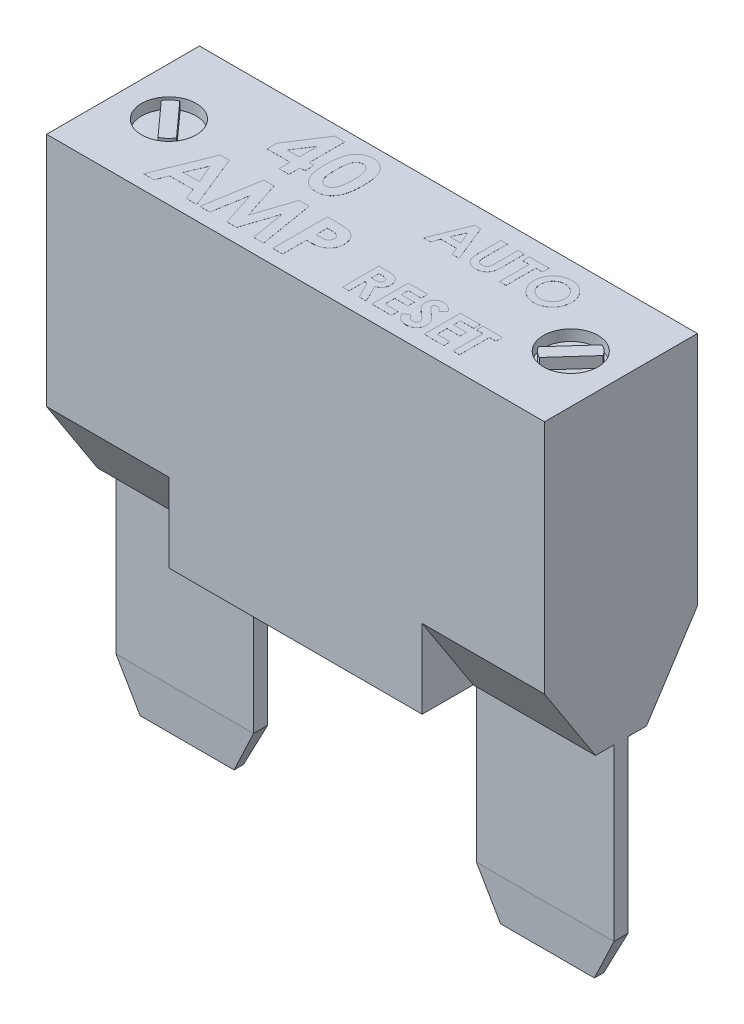
from build123d import *
from OCP.BRepFilletAPI import BRepFilletAPI_MakeChamfer

# Parameters (mm, degrees)
EXTRUDE1_DEPTH            = 14.478
SKETCH2_W                 = 8.89
SKETCH2_H                 = 18.288
EXTRUDE2_DEPTH            = 7.366
SKETCH3_W                 = 8.001
SKETCH3_H                 = 0.8128
EXTRUDE3_DEPTH            = 12.446
CHAMFER1_SIZE             = 2.54
CHAMFER1_SIZE2            = 0.133115759
CHAMFER2_SIZE             = 2.54
CHAMFER2_SIZE2            = 1.270274247
SKETCH4_R                 = 1.5875
EXTRUDE4_DEPTH            = 0.635
EXTRUDE5_DEPTH            = 0.635
CHAMFER1_OF_MIRROR1_SIZE  = 2.54
CHAMFER1_OF_MIRROR1_SIZE2 = 0.133115759
CHAMFER2_OF_MIRROR1_SIZE  = 2.54
CHAMFER2_OF_MIRROR1_SIZE2 = 1.270274247
EXTRUDE6_DEPTH            = 0.00254


with BuildPart() as part:
    # Sketch1 → Extrude1 (new, symmetric)
    with BuildSketch(Plane(origin=(0, 0, 0), x_dir=(0, 0, -1), z_dir=(1, 0, 0))):
        Polygon((-4.445, 4.572), (-1.481577724, 0), (1.481577724, 0), (4.445, 4.572), (4.445, 18.288), (-4.445, 18.288), align=None)
    extrude(amount=EXTRUDE1_DEPTH, both=True)

    # Sketch2 → Extrude2 (add, symmetric)
    with BuildSketch(Plane(origin=(0, 0, 0), x_dir=(0, 0, -1), z_dir=(1, 0, 0))):
        with Locations((0, 9.144)):
            Rectangle(SKETCH2_W, SKETCH2_H)
    extrude(amount=EXTRUDE2_DEPTH, both=True)

    # Sketch3 → Extrude3 (add)
    with BuildSketch(Plane.XZ):
        with Locations((-10.4775, 0)):
            Rectangle(SKETCH3_W, SKETCH3_H)
    extrude3 = extrude(amount=EXTRUDE3_DEPTH)

    # Chamfer1: one chamfer whose edges measure the first distance from different faces: ONE call of the kernel's chamfer builder (chamfer() names one face for all edges)
    chamfer1_edges_1 = [part.edges().sort_by_distance(p)[0] for p in [
        (-10.4775, -12.446, -0.4064),
    ]]
    chamfer1_side_1 = [part.faces().sort_by_distance(p)[0] for p in [
        (-10.4775, -6.223, -0.4064),
    ]]
    chamfer1_edges_2 = [part.edges().sort_by_distance(p)[0] for p in [
        (-10.4775, -12.446, 0.4064),
    ]]
    chamfer1_side_2 = [part.faces().sort_by_distance(p)[0] for p in [
        (-10.4775, -6.223, 0.4064),
    ]]
    chamfer1 = BRepFilletAPI_MakeChamfer(part.part.solid().wrapped)
    for e in chamfer1_edges_1:
        chamfer1.Add(CHAMFER1_SIZE, CHAMFER1_SIZE2, e.wrapped, chamfer1_side_1[0].wrapped)  # the first distance lies on this face
    for e in chamfer1_edges_2:
        chamfer1.Add(CHAMFER1_SIZE, CHAMFER1_SIZE2, e.wrapped, chamfer1_side_2[0].wrapped)  # the first distance lies on this face
    add(Compound.cast(chamfer1.Shape()), mode=Mode.REPLACE)

    # Chamfer2: one chamfer whose edges measure the first distance from different faces: ONE call of the kernel's chamfer builder (chamfer() names one face for all edges)
    chamfer2_edges_1 = [part.edges().sort_by_distance(p)[0] for p in [
        (-14.478, -12.446, 0),
    ]]
    chamfer2_side_1 = [part.faces().sort_by_distance(p)[0] for p in [
        (-14.478, 8.85938846, 0),
    ]]
    chamfer2_edges_2 = [part.edges().sort_by_distance(p)[0] for p in [
        (-6.477, -12.446, 0),
    ]]
    chamfer2_side_2 = [part.faces().sort_by_distance(p)[0] for p in [
        (-6.477, -6.037091359, 0),
    ]]
    chamfer2 = BRepFilletAPI_MakeChamfer(part.part.solid().wrapped)
    for e in chamfer2_edges_1:
        chamfer2.Add(CHAMFER2_SIZE, CHAMFER2_SIZE2, e.wrapped, chamfer2_side_1[0].wrapped)  # the first distance lies on this face
    for e in chamfer2_edges_2:
        chamfer2.Add(CHAMFER2_SIZE, CHAMFER2_SIZE2, e.wrapped, chamfer2_side_2[0].wrapped)  # the first distance lies on this face
    add(Compound.cast(chamfer2.Shape()), mode=Mode.REPLACE)

    # Sketch4 → Extrude4 (cut)
    with BuildSketch(Plane(origin=(0, 18.288, 0), x_dir=(1, 0, 0), z_dir=(0, 1, 0))):
        with Locations(Location((-11.684, -0.127, 0), (0, 0, 270))):
            Circle(SKETCH4_R)
        with Locations(Location((11.684, -0.127, 0), (0, 0, 90))):
            Circle(SKETCH4_R)
    extrude(amount=-EXTRUDE4_DEPTH, mode=Mode.SUBTRACT)

    # Sketch5 → Extrude5 (add)
    with BuildSketch(Plane(origin=(0, 17.653, 0), x_dir=(1, 0, 0), z_dir=(0, 1, 0))):
        with BuildLine():
            Line((-10.520386715, -0.849927911), (-12.281336928, 1.105805433))
            ThreePointArc((-12.281336928, 1.105805433), (-12.600640707, 0.89103264), (-12.847613285, 0.595927911))
            Line((-12.847613285, 0.595927911), (-11.086663072, -1.359805433))
            ThreePointArc((-11.086663072, -1.359805433), (-10.767359293, -1.14503264), (-10.520386715, -0.849927911))
        make_face()
    extrude5 = extrude(amount=EXTRUDE5_DEPTH)

    # Mirror1: Extrude3, Extrude5 across plane
    add(extrude3.mirror(Plane(origin=(0, 0, 0), x_dir=(0, 0, 1), z_dir=(1, 0, 0))))
    add(extrude5.mirror(Plane(origin=(0, 0, 0), x_dir=(0, 0, 1), z_dir=(1, 0, 0))))

    # Chamfer1 of Mirror1: one chamfer whose edges measure the first distance from different faces: ONE call of the kernel's chamfer builder (chamfer() names one face for all edges)
    chamfer1_of_mirror1_edges_1 = [part.edges().sort_by_distance(p)[0] for p in [
        (10.4775, -12.446, -0.4064),
    ]]
    chamfer1_of_mirror1_side_1 = [part.faces().sort_by_distance(p)[0] for p in [
        (10.4775, -6.223, -0.4064),
    ]]
    chamfer1_of_mirror1_edges_2 = [part.edges().sort_by_distance(p)[0] for p in [
        (10.4775, -12.446, 0.4064),
    ]]
    chamfer1_of_mirror1_side_2 = [part.faces().sort_by_distance(p)[0] for p in [
        (10.4775, -6.223, 0.4064),
    ]]
    chamfer1_of_mirror1 = BRepFilletAPI_MakeChamfer(part.part.solid().wrapped)
    for e in chamfer1_of_mirror1_edges_1:
        chamfer1_of_mirror1.Add(CHAMFER1_OF_MIRROR1_SIZE, CHAMFER1_OF_MIRROR1_SIZE2, e.wrapped, chamfer1_of_mirror1_side_1[0].wrapped)  # the first distance lies on this face
    for e in chamfer1_of_mirror1_edges_2:
        chamfer1_of_mirror1.Add(CHAMFER1_OF_MIRROR1_SIZE, CHAMFER1_OF_MIRROR1_SIZE2, e.wrapped, chamfer1_of_mirror1_side_2[0].wrapped)  # the first distance lies on this face
    add(Compound.cast(chamfer1_of_mirror1.Shape()), mode=Mode.REPLACE)

    # Chamfer2 of Mirror1: one chamfer whose edges measure the first distance from different faces: ONE call of the kernel's chamfer builder (chamfer() names one face for all edges)
    chamfer2_of_mirror1_edges_1 = [part.edges().sort_by_distance(p)[0] for p in [
        (14.478, -12.446, 0),
    ]]
    chamfer2_of_mirror1_side_1 = [part.faces().sort_by_distance(p)[0] for p in [
        (14.478, 8.85938846, 0),
    ]]
    chamfer2_of_mirror1_edges_2 = [part.edges().sort_by_distance(p)[0] for p in [
        (6.477, -12.446, 0),
    ]]
    chamfer2_of_mirror1_side_2 = [part.faces().sort_by_distance(p)[0] for p in [
        (6.477, -6.037091359, 0),
    ]]
    chamfer2_of_mirror1 = BRepFilletAPI_MakeChamfer(part.part.solid().wrapped)
    for e in chamfer2_of_mirror1_edges_1:
        chamfer2_of_mirror1.Add(CHAMFER2_OF_MIRROR1_SIZE, CHAMFER2_OF_MIRROR1_SIZE2, e.wrapped, chamfer2_of_mirror1_side_1[0].wrapped)  # the first distance lies on this face
    for e in chamfer2_of_mirror1_edges_2:
        chamfer2_of_mirror1.Add(CHAMFER2_OF_MIRROR1_SIZE, CHAMFER2_OF_MIRROR1_SIZE2, e.wrapped, chamfer2_of_mirror1_side_2[0].wrapped)  # the first distance lies on this face
    add(Compound.cast(chamfer2_of_mirror1.Shape()), mode=Mode.REPLACE)

    # Sketch7 → Extrude6 (add)
    with BuildSketch(Plane(origin=(0, 18.288, 0), x_dir=(1, 0, 0), z_dir=(0, 1, 0))):
        Polygon((-6.008239342, 3.833529575), (-5.414198877, 3.833529575), (-5.414198877, 1.757568037), (-5.129262979, 1.757568037), (-5.129262979, 1.22840137), (-5.414198877, 1.22840137), (-5.414198877, 0.577119319), (-5.984070672, 0.577119319), (-5.984070672, 1.22840137), (-7.327339903, 1.22840137), (-7.327339903, 1.805269359), align=None)
        Polygon((-5.984070672, 1.757568037), (-5.984070672, 2.838161987), (-6.686870151, 1.757568037), align=None, mode=Mode.SUBTRACT)
        with BuildLine():
            add(Edge.make_bspline(
                [(-3.775181449, 3.833529575), (-3.747597289, 3.833120081), (-3.69335946, 3.832314905), (-3.613477348, 3.823594194), (-3.536528788, 3.810419633), (-3.462212747, 3.792045714), (-3.391064161, 3.767728487), (-3.322565195, 3.738621183), (-3.257531185, 3.703197064), (-3.19513274, 3.663183703), (-3.135393895, 3.617882905), (-3.079750432, 3.566237656), (-3.027186183, 3.509436316), (-2.97883897, 3.44662015), (-2.933638131, 3.378360538), (-2.891732186, 3.304646657), (-2.853441936, 3.225117725), (-2.81833824, 3.139630227), (-2.786948404, 3.046902742), (-2.760508784, 2.945871645), (-2.737832386, 2.836513865), (-2.718691906, 2.718557193), (-2.704224796, 2.591844837), (-2.694473673, 2.456460977), (-2.687781991, 2.312666615), (-2.687235863, 2.214024865), (-2.686955287, 2.163347284)],
                knots=[0, 0, 0, 0, 0.879237366, 1.728815576, 2.559023295, 3.367336655, 4.166867292, 4.954216142, 5.737608147, 6.525189134, 7.316157332, 8.124696809, 8.942788509, 9.781158001, 10.649253743, 11.551476218, 12.482711956, 13.461909668, 14.496590415, 15.601789533, 16.789733467, 18.056700938, 19.410929216, 20.8549011, 22.384193279, 24, 24, 24, 24], degree=3))
            add(Edge.make_bspline(
                [(-2.686955287, 2.163347284), (-2.687258514, 2.112035669), (-2.687847677, 2.012338123), (-2.694195498, 1.867228544), (-2.705126746, 1.730861717), (-2.719215727, 1.603251749), (-2.738513778, 1.484466028), (-2.761114477, 1.374196981), (-2.787971439, 1.272484576), (-2.820395246, 1.179557993), (-2.855286458, 1.09392036), (-2.893681448, 1.01454649), (-2.934910995, 0.941221396), (-2.978029419, 0.872838869), (-3.025400628, 0.811414789), (-3.074718935, 0.754860419), (-3.128131744, 0.705329986), (-3.183390172, 0.660270913), (-3.242518556, 0.621330833), (-3.304907123, 0.58727448), (-3.371668151, 0.559650733), (-3.4415847, 0.535625073), (-3.515848514, 0.518377242), (-3.593279548, 0.504691655), (-3.674751986, 0.49712816), (-3.730221702, 0.496189858), (-3.758644991, 0.495709062)],
                knots=[0, 0, 0, 0, 1.643780988, 3.193836972, 4.651895693, 6.025988579, 7.305620092, 8.505800249, 9.631074763, 10.672816429, 11.65661981, 12.592235626, 13.49536222, 14.350718032, 15.179365177, 15.97804903, 16.751647189, 17.51006938, 18.259804725, 19.016521909, 19.783502495, 20.571750527, 21.382245291, 22.22305063, 23.089471752, 24, 24, 24, 24], degree=3))
            add(Edge.make_bspline(
                [(-3.758644991, 0.495709062), (-3.787067512, 0.496199133), (-3.842746812, 0.497159173), (-3.924439559, 0.504635417), (-4.00228094, 0.518432682), (-4.077132299, 0.535757489), (-4.148472683, 0.559597574), (-4.216644168, 0.588047803), (-4.281122573, 0.621891661), (-4.34208643, 0.660922469), (-4.399327589, 0.705680062), (-4.453735579, 0.755685708), (-4.505190045, 0.810812655), (-4.552908238, 0.87167837), (-4.597671644, 0.937470424), (-4.639013451, 1.008940129), (-4.676908813, 1.085983428), (-4.712543106, 1.168707711), (-4.743504795, 1.258893936), (-4.771059261, 1.357347456), (-4.793631155, 1.464888961), (-4.811784982, 1.581483903), (-4.826278988, 1.70688527), (-4.837060862, 1.84115359), (-4.843443942, 1.984351402), (-4.844026927, 2.082778391), (-4.844327082, 2.133454455)],
                knots=[0, 0, 0, 0, 0.917216111, 1.796812873, 2.643793957, 3.46689424, 4.273913431, 5.068098542, 5.848489301, 6.620921603, 7.401012384, 8.190319798, 9.003608147, 9.831726257, 10.68377682, 11.569763213, 12.493818149, 13.453288342, 14.474581811, 15.568529029, 16.750744269, 18.018426408, 19.375425659, 20.823733699, 22.36466933, 24, 24, 24, 24], degree=3))
            add(Edge.make_bspline(
                [(-4.844327082, 2.133454455), (-4.843783379, 2.203864856), (-4.842734297, 2.339722633), (-4.829439555, 2.535997619), (-4.809926247, 2.717419844), (-4.781265819, 2.883685834), (-4.745827597, 3.035411388), (-4.700447108, 3.171597018), (-4.648784722, 3.294127158), (-4.604761733, 3.366714751), (-4.583559854, 3.401673606)],
                knots=[0, 0, 0, 0, 1.288568992, 2.486310467, 3.599230591, 4.627010532, 5.572937695, 6.447898582, 7.252493626, 8, 8, 8, 8], degree=3))
            add(Edge.make_bspline(
                [(-4.583559854, 3.401673606), (-4.55890732, 3.436017174), (-4.510706758, 3.503165617), (-4.426426728, 3.591318971), (-4.335878809, 3.666712036), (-4.237203198, 3.727638599), (-4.131960491, 3.775685292), (-4.019247126, 3.80962013), (-3.899479335, 3.829392148), (-3.817232794, 3.832129838), (-3.775181449, 3.833529575)],
                knots=[0, 0, 0, 0, 1.058512271, 2.069600068, 3.047294572, 4.004278952, 4.967380941, 5.939006123, 6.946246673, 8, 8, 8, 8], degree=3))
        make_face()
        with BuildLine():
            add(Edge.make_bspline(
                [(-3.761189061, 3.26365778), (-3.786125371, 3.262475849), (-3.835013774, 3.260158636), (-3.905953177, 3.240488766), (-3.972844605, 3.21010759), (-4.023727127, 3.173548596), (-4.061812189, 3.138502416), (-4.088422495, 3.106786763), (-4.114083941, 3.07139438), (-4.136749423, 3.03072819), (-4.158151554, 2.986249378), (-4.179067887, 2.937756038), (-4.196213788, 2.884057066), (-4.21305918, 2.826066965), (-4.227817317, 2.762182461), (-4.240181399, 2.691881369), (-4.25122762, 2.614706515), (-4.258932491, 2.530607349), (-4.266115743, 2.43967186), (-4.271265038, 2.341697479), (-4.273417829, 2.236710636), (-4.274102136, 2.164407756), (-4.274455287, 2.127094279)],
                knots=[0, 0, 0, 0, 1.076674018, 2.110852608, 3.161083442, 4.239746716, 4.804137807, 5.395870207, 6.026861976, 6.692161227, 7.405688833, 8.16177676, 8.973626916, 9.841385931, 10.773283133, 11.807421078, 12.927755683, 14.143907515, 15.458935494, 16.872852025, 18.386167141, 20, 20, 20, 20], degree=3))
            add(Edge.make_bspline(
                [(-4.274455287, 2.127094279), (-4.273874043, 2.078752865), (-4.272759464, 1.986054621), (-4.266921819, 1.852751318), (-4.255220744, 1.731434579), (-4.240666969, 1.621282194), (-4.220225599, 1.523008532), (-4.196706478, 1.435683833), (-4.167662456, 1.360421274), (-4.134096492, 1.296132389), (-4.096920675, 1.241441969), (-4.05656469, 1.194954865), (-4.014402514, 1.154699227), (-3.969118128, 1.122000068), (-3.920819567, 1.09694094), (-3.869910036, 1.078916218), (-3.816357182, 1.067882536), (-3.77968474, 1.066352519), (-3.761189061, 1.065580857)],
                knots=[0, 0, 0, 0, 1.771748488, 3.397459088, 4.888034009, 6.237357457, 7.467047327, 8.564189669, 9.548206622, 10.417051504, 11.216568818, 11.965764335, 12.669334354, 13.348544111, 14.005342236, 14.656555988, 15.322436492, 16, 16, 16, 16], degree=3))
            add(Edge.make_bspline(
                [(-3.761189061, 1.065580857), (-3.743328096, 1.066108885), (-3.708358546, 1.067142698), (-3.657365111, 1.077754651), (-3.609142095, 1.095007382), (-3.563835099, 1.11941258), (-3.521282066, 1.150447524), (-3.481690969, 1.188248594), (-3.445360397, 1.233192579), (-3.42419404, 1.266547663), (-3.413287419, 1.283734904)],
                knots=[0, 0, 0, 0, 0.992283464, 1.942767638, 2.88273346, 3.832339453, 4.79467288, 5.803907806, 6.868395428, 8, 8, 8, 8], degree=3))
            add(Edge.make_bspline(
                [(-3.413287419, 1.283734904), (-3.400446709, 1.307220719), (-3.373520782, 1.356468569), (-3.342362053, 1.439572479), (-3.316134371, 1.533299955), (-3.293560589, 1.637942685), (-3.278121499, 1.753913393), (-3.264825374, 1.880476699), (-3.258412322, 2.018269924), (-3.257369204, 2.113733567), (-3.256827082, 2.163347284)],
                knots=[0, 0, 0, 0, 0.710965849, 1.490837728, 2.352621235, 3.297892224, 4.334225155, 5.461620853, 6.680770821, 8, 8, 8, 8], degree=3))
            add(Edge.make_bspline(
                [(-3.256827082, 2.163347284), (-3.257036492, 2.213391671), (-3.257439571, 2.309718575), (-3.264834896, 2.448007176), (-3.275133451, 2.574310862), (-3.290197265, 2.688347648), (-3.309579599, 2.790394366), (-3.333468398, 2.880444345), (-3.361631516, 2.958675056), (-3.395029618, 3.025008491), (-3.43202009, 3.081382812), (-3.471286606, 3.129747606), (-3.5129952, 3.171040248), (-3.557076122, 3.205416127), (-3.604549639, 3.231681878), (-3.654508947, 3.25022767), (-3.707056465, 3.261447253), (-3.742901311, 3.262910992), (-3.761189061, 3.26365778)],
                knots=[0, 0, 0, 0, 1.793836731, 3.452829483, 4.963243077, 6.335886805, 7.574563692, 8.684454726, 9.672768357, 10.54971625, 11.340229787, 12.085688095, 12.778991901, 13.440269426, 14.083255152, 14.715733572, 15.344777694, 16, 16, 16, 16], degree=3))
        make_face(mode=Mode.SUBTRACT)
        Polygon((-8.381308192, -0.44156083), (-7.852777543, -0.44156083), (-6.570566004, -3.61656083), (-7.179234874, -3.61656083), (-7.426009714, -2.965278779), (-8.809348055, -2.965278779), (-9.056122895, -3.61656083), (-9.664155748, -3.61656083), align=None)
        Polygon((-8.117360876, -1.293188434), (-8.593102062, -2.395406984), (-7.64161969, -2.395406984), align=None, mode=Mode.SUBTRACT)
        Polygon((-5.851230067, -0.44156083), (-5.259733672, -0.44156083), (-4.535309594, -2.656174212), (-3.805797374, -0.44156083), (-3.220025139, -0.44156083), (-2.683226261, -3.61656083), (-3.260094249, -3.61656083), (-3.599091645, -1.611197248), (-4.259277943, -3.61656083), (-4.81515735, -3.61656083), (-5.471527543, -1.611197248), (-5.809888921, -3.61656083), (-6.387392927, -3.61656083), align=None)
        with BuildLine():
            Line((-2.154059594, -0.44156083), (-1.518041966, -0.44156083))
            add(Edge.make_bspline(
                [(-1.518041966, -0.44156083), (-1.476485399, -0.441746846), (-1.396314071, -0.44210571), (-1.28070042, -0.446457413), (-1.174041166, -0.454255929), (-1.076360814, -0.463893661), (-0.987699528, -0.477405387), (-0.907946277, -0.492895523), (-0.837084511, -0.511767016), (-0.774315157, -0.534167218), (-0.71798169, -0.56057618), (-0.664672061, -0.58870361), (-0.615591073, -0.622272705), (-0.568261461, -0.657665532), (-0.52538914, -0.698263153), (-0.484299479, -0.741363737), (-0.446732736, -0.788676619), (-0.412514841, -0.839629089), (-0.381473939, -0.893279762), (-0.354354529, -0.949724551), (-0.332356783, -1.009052774), (-0.313903409, -1.070880643), (-0.29908148, -1.135205465), (-0.289215531, -1.202422844), (-0.282514083, -1.27206344), (-0.281922773, -1.319460875), (-0.281623696, -1.343433827)],
                knots=[0, 0, 0, 0, 1.698747864, 3.27724071, 4.728299578, 6.070144658, 7.288476769, 8.393259625, 9.389771311, 10.283485332, 11.113357557, 11.931608583, 12.74405601, 13.541433047, 14.344816069, 15.154114104, 15.974336324, 16.810834471, 17.661136416, 18.50621059, 19.367396281, 20.244825668, 21.142564693, 22.063065223, 23.020325768, 24, 24, 24, 24], degree=3))
            add(Edge.make_bspline(
                [(-0.281623696, -1.343433827), (-0.282056423, -1.369954533), (-0.282906782, -1.42207098), (-0.29124305, -1.498467297), (-0.305484029, -1.571304269), (-0.324096243, -1.641196142), (-0.350049653, -1.706993041), (-0.379700204, -1.770264899), (-0.416179788, -1.829237769), (-0.457863543, -1.884649328), (-0.50338696, -1.936950101), (-0.553830762, -1.98463), (-0.608233468, -2.028014057), (-0.66628016, -2.067556943), (-0.728188764, -2.103178888), (-0.79391461, -2.135213456), (-0.863906509, -2.162636081), (-0.912646763, -2.176977892), (-0.937357871, -2.184249131)],
                knots=[0, 0, 0, 0, 1.102006807, 2.165578795, 3.188629044, 4.184801286, 5.166646146, 6.124351954, 7.085497154, 8.042432466, 9.003981491, 9.963833307, 10.922997304, 11.89326795, 12.880200226, 13.889073926, 14.929769137, 16, 16, 16, 16], degree=3))
            add(Edge.make_bspline(
                [(-0.937357871, -2.184249131), (-0.953634029, -2.188298666), (-0.988893427, -2.197071261), (-1.047238047, -2.205977647), (-1.114474096, -2.214166522), (-1.190818991, -2.221203868), (-1.276316748, -2.225987624), (-1.370884582, -2.229723524), (-1.47456535, -2.23243991), (-1.546660856, -2.232536299), (-1.584187799, -2.232586471)],
                knots=[0, 0, 0, 0, 0.618981996, 1.340914327, 2.176866532, 3.120127938, 4.170906482, 5.338178032, 6.614476169, 8, 8, 8, 8], degree=3))
            Line((-1.584187799, -2.232586471), (-1.584187799, -3.61656083))
            Line((-1.584187799, -3.61656083), (-2.154059594, -3.61656083))
            Line((-2.154059594, -3.61656083), (-2.154059594, -0.44156083))
        make_face()
        with BuildLine():
            Line((-1.584187799, -1.662714676), (-1.382570211, -1.662714676))
            add(Edge.make_bspline(
                [(-1.382570211, -1.662714676), (-1.345882708, -1.662482049), (-1.278377157, -1.662054012), (-1.186188412, -1.655864339), (-1.112103764, -1.646411459), (-1.053575516, -1.632853843), (-1.007361921, -1.612278366), (-0.967505588, -1.588476413), (-0.933319794, -1.558379497), (-0.903719928, -1.523988621), (-0.880055728, -1.484471781), (-0.863645837, -1.440472431), (-0.852986295, -1.392915046), (-0.852001787, -1.359818253), (-0.851495491, -1.342797809)],
                knots=[0, 0, 0, 0, 1.8619151, 3.425951444, 4.686033666, 5.651700536, 6.461346321, 7.243864085, 7.999046032, 8.762387399, 9.539336099, 10.322741239, 11.137448474, 12, 12, 12, 12], degree=3))
            add(Edge.make_bspline(
                [(-0.851495491, -1.342797809), (-0.851996579, -1.327927269), (-0.852968809, -1.299074846), (-0.860111079, -1.257433642), (-0.871493802, -1.21861545), (-0.88798693, -1.183025674), (-0.90930864, -1.150724787), (-0.935304119, -1.121725514), (-0.965639794, -1.09540681), (-0.989060708, -1.081475918), (-1.000959634, -1.07439837)],
                knots=[0, 0, 0, 0, 1.102301479, 2.1387299, 3.123554645, 4.094223062, 5.036071848, 5.982632524, 6.975082478, 8, 8, 8, 8], degree=3))
            add(Edge.make_bspline(
                [(-1.000959634, -1.07439837), (-1.011038711, -1.069301092), (-1.032378182, -1.058509109), (-1.068721371, -1.045962641), (-1.110660855, -1.035378312), (-1.158479775, -1.026593422), (-1.211987366, -1.019775434), (-1.271174082, -1.01456138), (-1.336127021, -1.012464605), (-1.381297904, -1.011786106), (-1.404830828, -1.011432625)],
                knots=[0, 0, 0, 0, 0.656809284, 1.390599849, 2.23162475, 3.173112763, 4.218524733, 5.370385145, 6.63003504, 8, 8, 8, 8], degree=3))
            Line((-1.404830828, -1.011432625), (-1.584187799, -1.011432625))
            Line((-1.584187799, -1.011432625), (-1.584187799, -1.662714676))
        make_face(mode=Mode.SUBTRACT)
        Polygon((2.557586423, 3.413395415), (2.909940189, 3.413395415), (3.764747882, 1.296728748), (3.358968635, 1.296728748), (3.194452075, 1.730916783), (2.272226514, 1.730916783), (2.107709954, 1.296728748), (1.702354719, 1.296728748), align=None)
        Polygon((2.733551301, 2.845643679), (2.41639051, 2.110831313), (3.050712091, 2.110831313), align=None, mode=Mode.SUBTRACT)
        with BuildLine():
            Line((4.076820531, 3.413395415), (4.456735061, 3.413395415))
            Line((4.456735061, 3.413395415), (4.456735061, 2.036205244))
            add(Edge.make_bspline(
                [(4.456735061, 2.036205244), (4.456755719, 2.021927134), (4.45679562, 1.994349111), (4.458793058, 1.954783678), (4.460620853, 1.91841476), (4.463918712, 1.885282175), (4.468790781, 1.855371749), (4.473508534, 1.828491349), (4.479893545, 1.805122236), (4.489489196, 1.778522068), (4.504272945, 1.748635327), (4.52842877, 1.717486679), (4.556302526, 1.689059017), (4.589710828, 1.665396908), (4.627258805, 1.646256395), (4.668740148, 1.632075393), (4.714096381, 1.624192639), (4.745457729, 1.622989192), (4.761599511, 1.622369774)],
                knots=[0, 0, 0, 0, 1.155499968, 2.231836252, 3.205919964, 4.102923608, 4.924856345, 5.658536265, 6.31071849, 6.882491295, 7.94666036, 8.992281882, 10.060072772, 11.158554251, 12.289267114, 13.461410017, 14.693379945, 16, 16, 16, 16], degree=3))
            add(Edge.make_bspline(
                [(4.761599511, 1.622369774), (4.778748162, 1.622870184), (4.812185129, 1.623845899), (4.860278883, 1.633423597), (4.904838018, 1.648674572), (4.944919066, 1.6704416), (4.980482141, 1.696533197), (5.010585538, 1.726285795), (5.034343028, 1.759758735), (5.049827277, 1.79064007), (5.05852092, 1.819063651), (5.065037238, 1.844459041), (5.069814421, 1.874423088), (5.074148437, 1.908487838), (5.076752848, 1.947006136), (5.079576906, 1.989668214), (5.080611949, 2.036765977), (5.080788365, 2.069561033), (5.08088036, 2.086662643)],
                knots=[0, 0, 0, 0, 1.261321664, 2.459363699, 3.594844139, 4.716940403, 5.803436589, 6.833651888, 7.818396249, 8.814403945, 9.360733334, 10.004355033, 10.743453831, 11.592799886, 12.532235708, 13.585170094, 14.740740724, 16, 16, 16, 16], degree=3))
            Line((5.08088036, 2.086662643), (5.08088036, 3.413395415))
            Line((5.08088036, 3.413395415), (5.46079489, 3.413395415))
            Line((5.46079489, 3.413395415), (5.46079489, 2.150688417))
            add(Edge.make_bspline(
                [(5.46079489, 2.150688417), (5.460742132, 2.125106034), (5.460640684, 2.075913605), (5.45908274, 2.005220624), (5.455766159, 1.940653925), (5.452980613, 1.882194643), (5.447589628, 1.829921531), (5.441973487, 1.783611369), (5.434815232, 1.743428269), (5.424164179, 1.697684693), (5.405783614, 1.64501264), (5.376151734, 1.584363055), (5.33853598, 1.524983437), (5.294076038, 1.467527004), (5.243876697, 1.414151829), (5.189050984, 1.367295334), (5.130469943, 1.327659792), (5.067521443, 1.296214339), (5.000259058, 1.271689257), (4.928017276, 1.255209637), (4.85084536, 1.244075799), (4.79754126, 1.243006257), (4.770079746, 1.242455244)],
                knots=[0, 0, 0, 0, 1.170808336, 2.251350247, 3.235597562, 4.129743112, 4.929140599, 5.639994148, 6.264258765, 6.79612947, 7.788252245, 8.809469599, 9.879094798, 10.999557536, 12.129761673, 13.226370002, 14.293821979, 15.358369427, 16.438775801, 17.562147481, 18.744053101, 20, 20, 20, 20], degree=3))
            add(Edge.make_bspline(
                [(4.770079746, 1.242455244), (4.75183377, 1.242762574), (4.715834834, 1.243368928), (4.662892083, 1.248715391), (4.611712514, 1.256594068), (4.562392293, 1.268088245), (4.51476024, 1.282936575), (4.468829008, 1.301213836), (4.424769289, 1.322818079), (4.382827636, 1.347550591), (4.34305566, 1.374294546), (4.306706128, 1.403941345), (4.272528165, 1.434298497), (4.24150916, 1.466643558), (4.213416132, 1.500636961), (4.188306938, 1.536355747), (4.166218882, 1.573796742), (4.146596353, 1.613634818), (4.129801382, 1.6578948), (4.115642591, 1.708151036), (4.103273138, 1.76519124), (4.09408089, 1.829143921), (4.085747145, 1.899798299), (4.080472343, 1.977338439), (4.077712857, 2.061766566), (4.077125489, 2.120298836), (4.076820531, 2.150688417)],
                knots=[0, 0, 0, 0, 1.001158378, 1.975264943, 2.917723546, 3.841610987, 4.75185031, 5.653588123, 6.552117133, 7.442167995, 8.324307438, 9.179605724, 10.014504199, 10.831958861, 11.636465792, 12.43274043, 13.225645099, 14.020104002, 14.867201867, 15.819789774, 16.883317127, 18.068162734, 19.364263498, 20.787406516, 22.332041935, 24, 24, 24, 24], degree=3))
            Line((4.076820531, 2.150688417), (4.076820531, 3.413395415))
        make_face()
        Polygon((5.732162412, 3.413395415), (6.871906001, 3.413395415), (6.871906001, 3.033480885), (6.491991472, 3.033480885), (6.491991472, 1.296728748), (6.112076942, 1.296728748), (6.112076942, 3.033480885), (5.732162412, 3.033480885), align=None)
        with BuildLine():
            add(Edge.make_bspline(
                [(8.165141845, 3.467668919), (8.20194269, 3.46671608), (8.274595891, 3.464834958), (8.381442533, 3.449154342), (8.484409028, 3.423605027), (8.583448815, 3.388089631), (8.67831391, 3.341646216), (8.769338935, 3.285591484), (8.856197841, 3.218867435), (8.938000568, 3.143030632), (9.013601042, 3.06056142), (9.079108896, 2.971768652), (9.134971591, 2.878953037), (9.181270743, 2.781865872), (9.216536164, 2.679834784), (9.241283369, 2.573379996), (9.257182222, 2.462531793), (9.259010834, 2.387059276), (9.259940189, 2.348701905)],
                knots=[0, 0, 0, 0, 1.014329547, 2.002516266, 2.970391464, 3.935626869, 4.897733899, 5.877609409, 6.878433252, 7.912639331, 8.949961323, 9.958554974, 10.949718813, 11.932905612, 12.9188844, 13.919928257, 14.942845884, 16, 16, 16, 16], degree=3))
            add(Edge.make_bspline(
                [(9.259940189, 2.348701905), (9.258950466, 2.310776734), (9.257000185, 2.236043967), (9.241932429, 2.126217274), (9.216768479, 2.020902838), (9.182101186, 1.919862279), (9.136641727, 1.823585), (9.081868415, 1.731456287), (9.016335888, 1.644331115), (8.942434373, 1.562256238), (8.86107522, 1.487755676), (8.77490296, 1.422102185), (8.684315485, 1.366469894), (8.589445386, 1.320884286), (8.490089218, 1.285506974), (8.386492403, 1.26054571), (8.278661352, 1.245376245), (8.205331008, 1.243438703), (8.168109928, 1.242455244)],
                knots=[0, 0, 0, 0, 1.051557043, 2.072126891, 3.067553643, 4.050577992, 5.02905126, 6.015227836, 7.017913613, 8.04756643, 9.074058332, 10.072836633, 11.047628519, 12.017157415, 12.98668631, 13.966869689, 14.968021931, 16, 16, 16, 16], degree=3))
            add(Edge.make_bspline(
                [(8.168109928, 1.242455244), (8.129181141, 1.243337456), (8.052691395, 1.245070881), (7.94074831, 1.26155496), (7.833497162, 1.286385742), (7.731838923, 1.323444352), (7.634738289, 1.369770731), (7.542908688, 1.426824444), (7.456380981, 1.494511205), (7.375651504, 1.571097532), (7.302510403, 1.654899771), (7.237949034, 1.743429406), (7.183490088, 1.836010147), (7.139131571, 1.932685324), (7.104161098, 2.032854125), (7.079493402, 2.137126606), (7.064921606, 2.245252684), (7.06289184, 2.318694078), (7.061863266, 2.355910105)],
                knots=[0, 0, 0, 0, 1.067978421, 2.098431617, 3.099715153, 4.085208694, 5.062210972, 6.048429807, 7.046490867, 8.072918869, 9.098532598, 10.095778865, 11.076610158, 12.041847152, 13.011192615, 13.984257998, 14.978533688, 16, 16, 16, 16], degree=3))
            add(Edge.make_bspline(
                [(7.061863266, 2.355910105), (7.062186092, 2.3809471), (7.062827655, 2.430704064), (7.070555962, 2.504441346), (7.081682501, 2.576739374), (7.098138124, 2.647309896), (7.1181275, 2.716650755), (7.144026561, 2.784116508), (7.173506701, 2.850427875), (7.207951469, 2.914801636), (7.246250721, 2.976645498), (7.288038614, 3.035667733), (7.333420225, 3.091154676), (7.382249363, 3.143470965), (7.4346943, 3.192272721), (7.490065178, 3.238250799), (7.549435869, 3.28018386), (7.611506935, 3.319095992), (7.675928434, 3.354283558), (7.742438112, 3.384234162), (7.809665737, 3.410389514), (7.87850938, 3.431032475), (7.94823126, 3.44784595), (8.019576213, 3.45896499), (8.091899679, 3.466693082), (8.14066985, 3.467342868), (8.165141845, 3.467668919)],
                knots=[0, 0, 0, 0, 1.034744296, 2.056386356, 3.06226378, 4.057406941, 5.050368692, 6.043467995, 7.042652155, 8.049140477, 9.059438543, 10.048523776, 11.036952808, 12.020949711, 13.004946614, 13.997082645, 14.994316842, 16.007702937, 17.024872941, 18.026463647, 19.021641123, 20.005082605, 20.995858141, 21.984425357, 22.988620895, 24, 24, 24, 24], degree=3))
        make_face()
        with BuildLine():
            add(Edge.make_bspline(
                [(8.159205681, 3.087754389), (8.134438718, 3.087089836), (8.085558643, 3.085778274), (8.013860476, 3.075785944), (7.945027703, 3.059827058), (7.879441892, 3.036710807), (7.816818788, 3.007289685), (7.757047381, 2.971666495), (7.70095538, 2.928616728), (7.647794852, 2.880451536), (7.599773063, 2.826784442), (7.557344298, 2.769271025), (7.521838255, 2.708007329), (7.492101722, 2.643562481), (7.469716703, 2.575211815), (7.453772526, 2.50349073), (7.4436964, 2.428275645), (7.442426292, 2.377001621), (7.441777796, 2.350821964)],
                knots=[0, 0, 0, 0, 1.033739768, 2.040188636, 3.016340934, 3.979330865, 4.937572243, 5.900995986, 6.878200029, 7.884839167, 8.891893314, 9.879764717, 10.863503415, 11.843163062, 12.837761627, 13.859916423, 14.907309254, 16, 16, 16, 16], degree=3))
            add(Edge.make_bspline(
                [(7.441777796, 2.350821964), (7.442637603, 2.321809016), (7.444322681, 2.264948445), (7.456179097, 2.182001775), (7.476464245, 2.103666878), (7.505755603, 2.030326878), (7.542084573, 1.961167389), (7.587199387, 1.89703606), (7.6403694, 1.8375489), (7.681331147, 1.802817819), (7.702121012, 1.785190287)],
                knots=[0, 0, 0, 0, 1.078454662, 2.113592447, 3.107694534, 4.079536787, 5.043276885, 6.005368276, 6.987637804, 8, 8, 8, 8], degree=3))
            add(Edge.make_bspline(
                [(7.702121012, 1.785190287), (7.719151881, 1.772167744), (7.752829909, 1.746416057), (7.806587375, 1.713409988), (7.861946979, 1.685120494), (7.91932648, 1.662262917), (7.978604694, 1.644283532), (8.039773494, 1.631692864), (8.102746207, 1.623791131), (8.145331307, 1.622846724), (8.166837892, 1.622369774)],
                knots=[0, 0, 0, 0, 1.023928204, 2.024787132, 3.009472467, 3.9914905, 4.972207045, 5.96565515, 6.972602802, 8, 8, 8, 8], degree=3))
            add(Edge.make_bspline(
                [(8.166837892, 1.622369774), (8.191178987, 1.623039962), (8.239070856, 1.624358578), (8.309434324, 1.634227896), (8.376844663, 1.650930347), (8.441720362, 1.673843814), (8.50387435, 1.703634344), (8.563002862, 1.740362453), (8.619209567, 1.78357717), (8.672302368, 1.832374877), (8.720831699, 1.886253382), (8.763171924, 1.94407357), (8.799806881, 2.004561491), (8.828925043, 2.068573257), (8.852194443, 2.13550463), (8.867946725, 2.205652032), (8.87810797, 2.27872629), (8.879378436, 2.328455906), (8.88002566, 2.353790047)],
                knots=[0, 0, 0, 0, 1.026359118, 2.019393844, 2.989460624, 3.950973911, 4.916101784, 5.890408035, 6.881132271, 7.902007068, 8.92769091, 9.933912415, 10.920395702, 11.90457117, 12.894218921, 13.903490204, 14.931958862, 16, 16, 16, 16], degree=3))
            add(Edge.make_bspline(
                [(8.88002566, 2.353790047), (8.879356042, 2.378978509), (8.878038003, 2.428558157), (8.868151314, 2.501444541), (8.851554786, 2.571282264), (8.828572511, 2.638185375), (8.799225364, 2.702219467), (8.762934639, 2.763159356), (8.719827676, 2.820946129), (8.670896579, 2.875185992), (8.617638087, 2.925028951), (8.560459775, 2.968283579), (8.500961556, 3.005870475), (8.437778249, 3.035314532), (8.372202534, 3.05877255), (8.303834263, 3.076047371), (8.232414487, 3.085708077), (8.183826137, 3.087066205), (8.159205681, 3.087754389)],
                knots=[0, 0, 0, 0, 1.055025985, 2.07665775, 3.074803781, 4.057872707, 5.035505728, 6.020516407, 7.023567878, 8.050795229, 9.077271434, 10.074415901, 11.050397877, 12.019801805, 12.988065821, 13.964604439, 14.968634123, 16, 16, 16, 16], degree=3))
        make_face(mode=Mode.SUBTRACT)
        with BuildLine():
            Line((1.82253207, -1.424321113), (2.26520034, -1.424321113))
            add(Edge.make_bspline(
                [(2.26520034, -1.424321113), (2.294460577, -1.42442497), (2.350736257, -1.424624717), (2.431882713, -1.427776185), (2.506426893, -1.432161712), (2.574479165, -1.438854143), (2.636010416, -1.447727497), (2.691082314, -1.458187714), (2.73969325, -1.470109373), (2.782253191, -1.484964701), (2.820661432, -1.501721285), (2.856463253, -1.520974908), (2.890448494, -1.542511175), (2.922390002, -1.566896761), (2.952565355, -1.593692978), (2.981031481, -1.622926798), (3.007386127, -1.654846111), (3.031466104, -1.689249229), (3.053413065, -1.72544052), (3.072809576, -1.763469675), (3.08858285, -1.803363141), (3.102520229, -1.84454437), (3.112558872, -1.887602058), (3.119540601, -1.932117029), (3.12465235, -1.978245982), (3.124946251, -2.009583945), (3.125096173, -2.025569778)],
                knots=[0, 0, 0, 0, 1.749336639, 3.364467119, 4.854658419, 6.213483162, 7.451590619, 8.570285859, 9.5643256, 10.440900261, 11.26203566, 12.067320669, 12.869050712, 13.665104639, 14.467235401, 15.27997916, 16.102287765, 16.939272006, 17.78853747, 18.631303466, 19.488103222, 20.351255419, 21.228522269, 22.127379805, 23.044756219, 24, 24, 24, 24], degree=3))
            add(Edge.make_bspline(
                [(3.125096173, -2.025569778), (3.124706729, -2.042255315), (3.123943101, -2.074972613), (3.119829783, -2.123031654), (3.112311931, -2.169011184), (3.10092505, -2.212776579), (3.08783731, -2.254872551), (3.070433972, -2.294522402), (3.050792586, -2.332302783), (3.027465085, -2.367679276), (3.001864292, -2.401437663), (2.972091108, -2.432284535), (2.940074379, -2.461877794), (2.904014327, -2.48836382), (2.865500513, -2.513533502), (2.823767708, -2.536343936), (2.779088275, -2.557368526), (2.747676421, -2.569093289), (2.731613267, -2.575089008)],
                knots=[0, 0, 0, 0, 1.099860209, 2.156625411, 3.176576793, 4.16617041, 5.135385252, 6.078461593, 7.016046972, 7.938469504, 8.868247731, 9.803980173, 10.76021508, 11.73834243, 12.748633912, 13.790971185, 14.870363756, 16, 16, 16, 16], degree=3))
            Line((2.731613267, -2.575089008), (3.220074805, -3.54098778))
            Line((3.220074805, -3.54098778), (2.7977591, -3.54098778))
            Line((2.7977591, -3.54098778), (2.331346173, -2.618338207))
            Line((2.331346173, -2.618338207), (2.2024466, -2.618338207))
            Line((2.2024466, -2.618338207), (2.2024466, -3.54098778))
            Line((2.2024466, -3.54098778), (1.82253207, -3.54098778))
            Line((1.82253207, -3.54098778), (1.82253207, -1.424321113))
        make_face()
        with BuildLine():
            Line((2.2024466, -2.238423677), (2.350426702, -2.238423677))
            add(Edge.make_bspline(
                [(2.350426702, -2.238423677), (2.368518499, -2.238219915), (2.403160404, -2.237829755), (2.452980013, -2.236020029), (2.498228099, -2.231659484), (2.539098973, -2.226150099), (2.575798294, -2.219788718), (2.607998716, -2.210672473), (2.636196399, -2.200904185), (2.660057198, -2.188764738), (2.680443318, -2.174959553), (2.698045427, -2.15927652), (2.712604895, -2.141125407), (2.72458808, -2.120999481), (2.733909695, -2.098720735), (2.740713759, -2.074533739), (2.744516225, -2.048162971), (2.744953712, -2.02996355), (2.745181643, -2.020481637)],
                knots=[0, 0, 0, 0, 1.688639943, 3.233382647, 4.650958383, 5.928841754, 7.082724185, 8.122798841, 9.049171256, 9.863274652, 10.613301712, 11.341792392, 12.054588806, 12.776240173, 13.521029143, 14.301969904, 15.115324896, 16, 16, 16, 16], degree=3))
            add(Edge.make_bspline(
                [(2.745181643, -2.020481637), (2.744750719, -2.009263841), (2.743904248, -1.98722856), (2.735504627, -1.955505482), (2.722134244, -1.926143602), (2.703807111, -1.899275586), (2.680726471, -1.875721228), (2.654239615, -1.854957875), (2.623774893, -1.838539768), (2.595566852, -1.827710559), (2.569904129, -1.821231332), (2.546744331, -1.81640307), (2.519925146, -1.812981141), (2.489426326, -1.809351577), (2.455325614, -1.806997989), (2.417437141, -1.805280338), (2.375869722, -1.804577563), (2.346893283, -1.804352898), (2.331770185, -1.804235643)],
                knots=[0, 0, 0, 0, 1.020303359, 2.004196876, 2.966617323, 3.9489082, 4.950758222, 5.960522915, 7.003732012, 8.091992268, 8.70421221, 9.413913587, 10.24622431, 11.166358409, 12.212345909, 13.359657661, 14.621978493, 16, 16, 16, 16], degree=3))
            Line((2.331770185, -1.804235643), (2.2024466, -1.804235643))
            Line((2.2024466, -1.804235643), (2.2024466, -2.238423677))
        make_face(mode=Mode.SUBTRACT)
        Polygon((3.532147455, -1.424321113), (4.671891045, -1.424321113), (4.671891045, -1.804235643), (3.912061985, -1.804235643), (3.912061985, -2.211286925), (4.671891045, -2.211286925), (4.671891045, -2.591201455), (3.912061985, -2.591201455), (3.912061985, -3.16107325), (4.671891045, -3.16107325), (4.671891045, -3.54098778), (3.532147455, -3.54098778), align=None)
        with BuildLine():
            Line((6.13727566, -1.707136952), (5.853187786, -1.967056156))
            add(Edge.make_bspline(
                [(5.853187786, -1.967056156), (5.84101868, -1.949890366), (5.817655693, -1.916934444), (5.779786727, -1.872805687), (5.74208876, -1.835160574), (5.704212541, -1.804156367), (5.665822351, -1.779981442), (5.626984829, -1.762865327), (5.587920157, -1.751984451), (5.561674728, -1.75062952), (5.548747348, -1.749962139)],
                knots=[0, 0, 0, 0, 1.299362458, 2.494594718, 3.587462134, 4.587049575, 5.512617175, 6.380583204, 7.202344345, 8, 8, 8, 8], degree=3))
            add(Edge.make_bspline(
                [(5.548747348, -1.749962139), (5.536689059, -1.750385022), (5.513407672, -1.751201499), (5.480218327, -1.759317215), (5.450752354, -1.77332375), (5.42503851, -1.791638473), (5.404669352, -1.813703468), (5.388406159, -1.836843975), (5.379248615, -1.862385861), (5.378043302, -1.879929058), (5.3774466, -1.888613982)],
                knots=[0, 0, 0, 0, 1.185010067, 2.2879431, 3.333075148, 4.379039566, 5.372662701, 6.27520591, 7.14612461, 8, 8, 8, 8], degree=3))
            add(Edge.make_bspline(
                [(5.3774466, -1.888613982), (5.377820523, -1.897424146), (5.378573551, -1.915166591), (5.385846777, -1.941170355), (5.396809605, -1.96657906), (5.407285035, -1.982046547), (5.412639576, -1.98995279)],
                knots=[0, 0, 0, 0, 0.967525499, 1.948461899, 2.951351359, 4, 4, 4, 4], degree=3))
            add(Edge.make_bspline(
                [(5.412639576, -1.98995279), (5.417507433, -1.996098231), (5.428712597, -2.010244223), (5.45007855, -2.032649269), (5.476909701, -2.060097412), (5.510238567, -2.09164479), (5.548681576, -2.12842597), (5.594020611, -2.168995071), (5.644950618, -2.21460847), (5.681150487, -2.246371989), (5.700119544, -2.263016359)],
                knots=[0, 0, 0, 0, 0.473873513, 1.090794244, 1.870441696, 2.795289791, 3.865433203, 5.087734844, 6.473946851, 8, 8, 8, 8], degree=3))
            add(Edge.make_bspline(
                [(5.700119544, -2.263016359), (5.717924732, -2.278425851), (5.751715281, -2.307669867), (5.799792522, -2.349177052), (5.842044409, -2.386520054), (5.879086457, -2.419138435), (5.910357144, -2.447374436), (5.935987932, -2.471363025), (5.956291857, -2.490637188), (5.96783345, -2.502278794), (5.9727591, -2.507247128)],
                knots=[0, 0, 0, 0, 1.543621617, 2.929473131, 4.163658386, 5.240097082, 6.164993805, 6.925417477, 7.541396219, 8, 8, 8, 8], degree=3))
            add(Edge.make_bspline(
                [(5.9727591, -2.507247128), (5.991445992, -2.527470347), (6.02736876, -2.566346476), (6.074055695, -2.626592249), (6.112480553, -2.685404408), (6.142206751, -2.743889598), (6.164657172, -2.802891646), (6.180485016, -2.863857573), (6.189964417, -2.927424434), (6.191016852, -2.970801057), (6.191549164, -2.992740584)],
                knots=[0, 0, 0, 0, 1.206664779, 2.319633467, 3.337109185, 4.282041471, 5.190008762, 6.099243693, 7.03861361, 8, 8, 8, 8], degree=3))
            add(Edge.make_bspline(
                [(6.191549164, -2.992740584), (6.191170278, -3.014117963), (6.190426889, -3.056061176), (6.181321794, -3.117438819), (6.168338464, -3.176179889), (6.148263958, -3.231645197), (6.12379727, -3.284745191), (6.093124741, -3.334652741), (6.057104063, -3.381872932), (6.015818835, -3.425561646), (5.97015247, -3.465206125), (5.921170954, -3.500498577), (5.86839532, -3.529636992), (5.812276475, -3.553630398), (5.752844459, -3.57211044), (5.690170073, -3.585768913), (5.624157452, -3.593966514), (5.57901707, -3.594823476), (5.555955548, -3.595261284)],
                knots=[0, 0, 0, 0, 1.043214005, 2.046824704, 3.02475056, 3.976699089, 4.921714032, 5.875962561, 6.831408892, 7.817874052, 8.806269674, 9.781291748, 10.760897367, 11.74438705, 12.757449933, 13.795994037, 14.874007457, 16, 16, 16, 16], degree=3))
            add(Edge.make_bspline(
                [(5.555955548, -3.595261284), (5.537852449, -3.594940123), (5.501997932, -3.59430404), (5.449153793, -3.589110952), (5.398126804, -3.580729859), (5.348974441, -3.56871725), (5.301475264, -3.553495646), (5.255627323, -3.534903039), (5.211747121, -3.512651251), (5.16950264, -3.487197867), (5.12909924, -3.457643136), (5.090026036, -3.424591295), (5.05267114, -3.38753399), (5.016855145, -3.346558862), (4.98280721, -3.301549878), (4.949412825, -3.253133872), (4.918156137, -3.200412309), (4.89884749, -3.163427706), (4.888985062, -3.144536792)],
                knots=[0, 0, 0, 0, 1.016823716, 2.013894106, 2.979844003, 3.91962641, 4.853723003, 5.779685073, 6.695824784, 7.614987388, 8.547259901, 9.504950863, 10.487499108, 11.500346958, 12.559593716, 13.656357062, 14.802919212, 16, 16, 16, 16], degree=3))
            Line((4.888985062, -3.144536792), (5.223106322, -2.943979233))
            add(Edge.make_bspline(
                [(5.223106322, -2.943979233), (5.235442746, -2.965422889), (5.259092724, -3.00653221), (5.299169824, -3.061767793), (5.340226766, -3.109067927), (5.383212751, -3.147596579), (5.427605085, -3.177868926), (5.473618193, -3.199503645), (5.521284404, -3.212895512), (5.553752461, -3.214530968), (5.569947936, -3.215346754)],
                knots=[0, 0, 0, 0, 1.283663364, 2.460892379, 3.537111102, 4.529833553, 5.449777664, 6.316464042, 7.160231139, 8, 8, 8, 8], degree=3))
            add(Edge.make_bspline(
                [(5.569947936, -3.215346754), (5.586421052, -3.214680539), (5.618381296, -3.213387985), (5.664000456, -3.201449049), (5.705825828, -3.182704044), (5.741979371, -3.155957507), (5.772591912, -3.125087938), (5.795185724, -3.090744131), (5.809379309, -3.053584961), (5.810879916, -3.027771758), (5.811634634, -3.014789195)],
                knots=[0, 0, 0, 0, 1.13588714, 2.203786484, 3.234766741, 4.283437687, 5.291419208, 6.222934724, 7.106237994, 8, 8, 8, 8], degree=3))
            add(Edge.make_bspline(
                [(5.811634634, -3.014789195), (5.810937682, -3.002711034), (5.809521891, -2.978175405), (5.799093609, -2.94169487), (5.782791024, -2.905230925), (5.763503916, -2.875322212), (5.743876868, -2.850280456), (5.725108983, -2.828582908), (5.702254665, -2.804610916), (5.675371861, -2.778334325), (5.644815763, -2.749521815), (5.610560631, -2.718176209), (5.57221421, -2.684573623), (5.545110883, -2.661683873), (5.530938855, -2.649715077)],
                knots=[0, 0, 0, 0, 0.916159276, 1.861089862, 2.860218735, 3.940849679, 4.552606315, 5.27541173, 6.11797699, 7.06649574, 8.129236253, 9.306560635, 10.591630461, 12, 12, 12, 12], degree=3))
            add(Edge.make_bspline(
                [(5.530938855, -2.649715077), (5.503997264, -2.626919908), (5.452288198, -2.583169079), (5.379216726, -2.518550482), (5.313372788, -2.458158483), (5.255325081, -2.401246503), (5.204333989, -2.348865576), (5.160744845, -2.300590243), (5.125036496, -2.256048127), (5.087461158, -2.20329097), (5.051757074, -2.13900275), (5.020898614, -2.061656569), (5.000878947, -1.984320202), (4.998636022, -1.932400824), (4.99753207, -1.906846487)],
                knots=[0, 0, 0, 0, 1.345494975, 2.582412109, 3.71882943, 4.751509156, 5.681369928, 6.505683931, 7.230279997, 7.856715994, 8.973648664, 10.023341002, 11.027102913, 12, 12, 12, 12], degree=3))
            add(Edge.make_bspline(
                [(4.99753207, -1.906846487), (4.997991202, -1.888724723), (4.998895741, -1.8530229), (5.00696437, -1.800528572), (5.019023244, -1.749875956), (5.03653619, -1.701249856), (5.059265879, -1.654711178), (5.086870204, -1.610032096), (5.119777807, -1.567623826), (5.156862454, -1.527514481), (5.197720241, -1.490859105), (5.241381978, -1.458507062), (5.287600536, -1.431182057), (5.336093174, -1.408513981), (5.387160381, -1.391163008), (5.440425945, -1.378863774), (5.495966269, -1.371548582), (5.533743598, -1.370554167), (5.552987466, -1.370047609)],
                knots=[0, 0, 0, 0, 1.010766082, 1.991317756, 2.957454644, 3.913069143, 4.869106762, 5.843196583, 6.838735724, 7.860187025, 8.887984031, 9.89767229, 10.887916223, 11.879572884, 12.879850636, 13.892031539, 14.926195476, 16, 16, 16, 16], degree=3))
            add(Edge.make_bspline(
                [(5.552987466, -1.370047609), (5.577926566, -1.370959934), (5.627607906, -1.372777384), (5.701063201, -1.386989243), (5.772811262, -1.409338889), (5.830627194, -1.436301278), (5.876630251, -1.462419757), (5.911887298, -1.486466362), (5.947763241, -1.514013041), (5.984547396, -1.545146601), (6.021556259, -1.580453637), (6.059842167, -1.61909364), (6.098883429, -1.661400548), (6.124254059, -1.691624407), (6.13727566, -1.707136952)],
                knots=[0, 0, 0, 0, 1.282922637, 2.555718331, 3.837320111, 5.142675274, 5.830281639, 6.55870424, 7.337177975, 8.157850921, 9.037902056, 9.96903443, 10.957596896, 12, 12, 12, 12], degree=3))
        make_face()
        Polygon((6.571463694, -1.424321113), (7.711207284, -1.424321113), (7.711207284, -1.804235643), (6.951378224, -1.804235643), (6.951378224, -2.211286925), (7.711207284, -2.211286925), (7.711207284, -2.591201455), (6.951378224, -2.591201455), (6.951378224, -3.16107325), (7.711207284, -3.16107325), (7.711207284, -3.54098778), (6.571463694, -3.54098778), align=None)
        Polygon((7.874027797, -1.424321113), (9.013771387, -1.424321113), (9.013771387, -1.804235643), (8.633856857, -1.804235643), (8.633856857, -3.54098778), (8.253942327, -3.54098778), (8.253942327, -1.804235643), (7.874027797, -1.804235643), align=None)
    extrude(amount=EXTRUDE6_DEPTH)


solid = part.part
